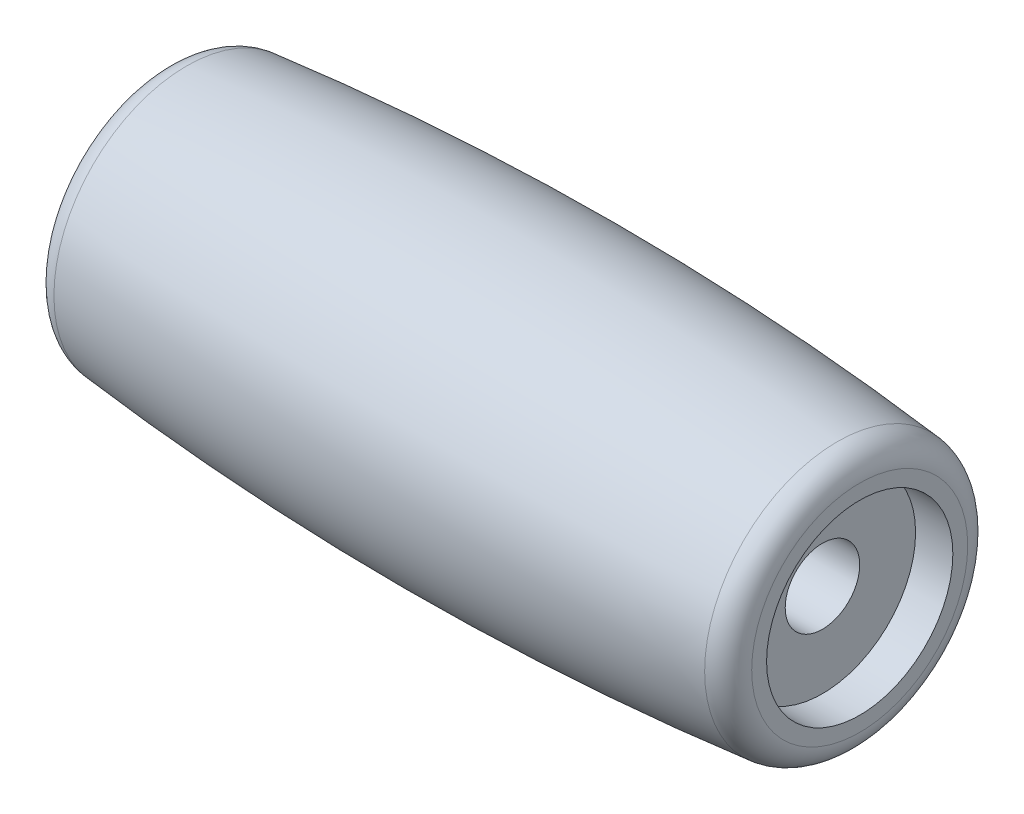
from build123d import *

# Parameters (mm, degrees)
SCALE1_SCALE = 1.667


with BuildPart() as part:
    # Sketch1 → Revolve1 (revolve)
    with BuildSketch(Plane.XY):
        with BuildLine():
            Line((-12.5, 1.5), (12.5, 1.5))
            Line((12.5, 1.5), (12.5, 3.75))
            Line((12.5, 3.75), (14, 3.75))
            Line((14, 3.75), (14, 4.348576665))
            ThreePointArc((14, 4.348576665), (13.741609048, 5.019408999), (13.099967959, 5.343567322))
            ThreePointArc((13.099967959, 5.343567322), (0, 6), (-13.099967959, 5.343567322))
            ThreePointArc((-13.099967959, 5.343567322), (-13.741609048, 5.019408999), (-14, 4.348576665))
            Line((-14, 4.348576665), (-14, 3.75))
            Line((-14, 3.75), (-12.5, 3.75))
            Line((-12.5, 3.75), (-12.5, 1.5))
        make_face()
    revolve(axis=Axis((-13.631775834, 0, 0), (1, 0, 0)))


with BuildPart() as part_1:
    # Scale1: scaled about (0, 0, 0)
    add(part.part.scale(SCALE1_SCALE))


solid = part_1.part
